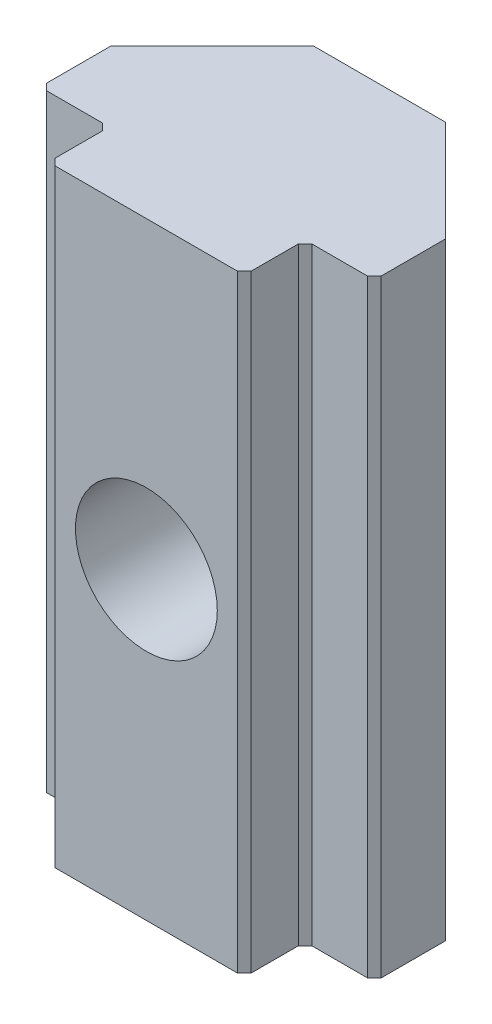
from build123d import *

# Parameters (mm, degrees)
EXTRUDE_1_DEPTH    = 18
CHAMFER_1_SIZE     = 3
CHAMFER_2_SIZE     = 0.2
HOLE_WIZARD_M5_1_D = 4.2


with BuildPart() as part:
    # 草图1 → 凸台-拉伸1 (new body)
    with BuildSketch(Plane(origin=(0, 0, 0), x_dir=(1, 0, 0), z_dir=(0, 1, 0))):
        Polygon((2.9, -2.55), (4.95, -2.55), (4.95, 2.55), (-4.95, 2.55), (-4.95, -2.55), (-2.9, -2.55), (-2.9, -4.35), (2.9, -4.35), align=None)
    extrude(amount=EXTRUDE_1_DEPTH)

    # 倒角1
    chamfer_1_edges = [part.edges().sort_by_distance(p)[0] for p in [
        (-4.95, 9, -2.55),
        (4.95, 9, -2.55),
    ]]
    chamfer(chamfer_1_edges, length=CHAMFER_1_SIZE)

    # 倒角2
    chamfer_2_edges = [part.edges().sort_by_distance(p)[0] for p in [
        (4.95, 9, 2.55),
        (2.9, 9, 2.55),
        (2.9, 9, 4.35),
        (-2.9, 9, 4.35),
        (-2.9, 9, 2.55),
        (-4.95, 9, 2.55),
    ]]
    chamfer(chamfer_2_edges, length=CHAMFER_2_SIZE)

    # M5 螺纹孔1 (through all)
    with Locations(Plane.XY.offset(4.35)):
        with Locations((0, 9)):
            Hole(HOLE_WIZARD_M5_1_D / 2)


solid = part.part
